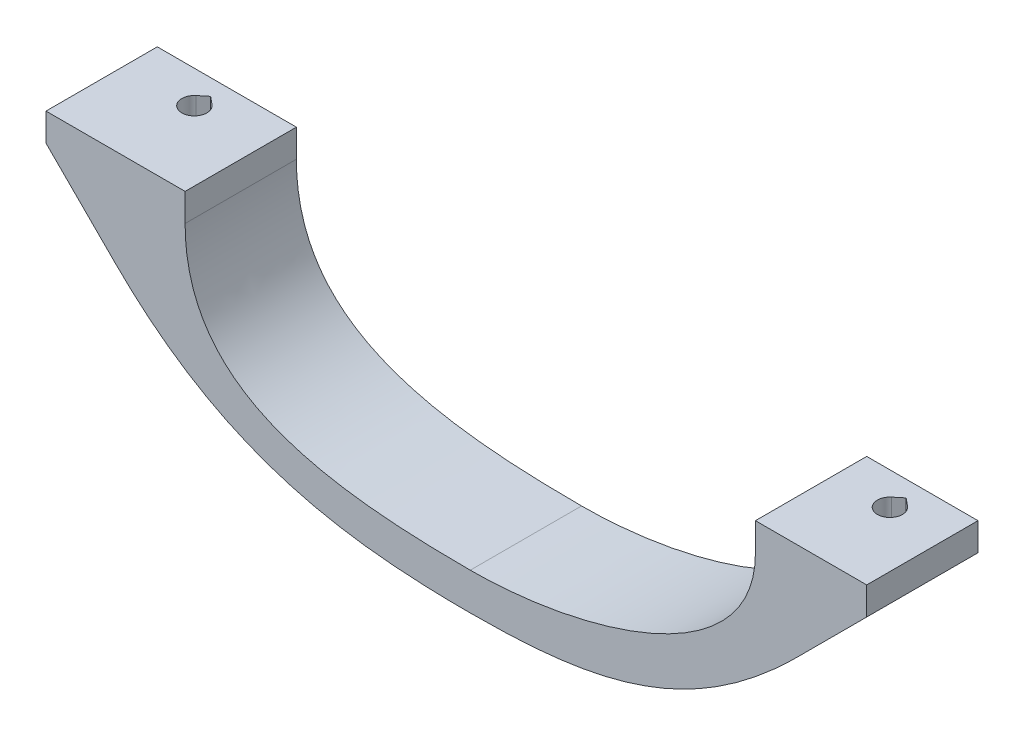
from build123d import *

# Parameters (mm, degrees)
BOSS_EXTRUDE1_DEPTH = 12
SKETCH2_R           = 1.35
CUT_EXTRUDE1_DEPTH  = 25.0000001
SKETCH4_R           = 2.5
CUT_EXTRUDE3_DEPTH  = 37
CUT_EXTRUDE4_DEPTH  = 25.0000001
CUT_EXTRUDE5_DEPTH  = 25.0000001


with BuildPart() as part:
    # Sketch1 → Boss-Extrude1 (new body)
    with BuildSketch(Plane.XY):
        with BuildLine():
            Line((88.5, -40), (76.5, -40))
            Line((76.5, -40), (76.5, -43))
            add(Edge.make_bspline(
                [(76.5, -43), (76.5, -54.661574252), (58.353185223, -60), (45.75, -60)],
                knots=[0, 0, 0, 0, 1, 1, 1, 1], degree=3))
            add(Edge.make_bspline(
                [(15, -43), (15, -57.889510146), (29.668022887, -60), (45.75, -60)],
                knots=[0, 0, 0, 0, 1, 1, 1, 1], degree=3))
            Line((15, -43), (15, -40))
            Line((15, -40), (0, -40))
            Line((0, -40), (0, -43))
            Line((0, -43), (7.5, -50.5))
            add(Edge.make_bspline(
                [(7.5, -50.5), (19.073181247, -62.073181247), (31.728934499, -64), (45.75, -64)],
                knots=[0, 0, 0, 0, 1, 1, 1, 1], degree=3))
            add(Edge.make_bspline(
                [(81, -50.5), (69.44210318, -62.05789682), (59.019901197, -64), (45.75, -64)],
                knots=[0, 0, 0, 0, 1, 1, 1, 1], degree=3))
            Line((81, -50.5), (88.5, -43))
            Line((88.5, -43), (88.5, -40))
        make_face()
    extrude(amount=-BOSS_EXTRUDE1_DEPTH)

    # Sketch2 → Cut-Extrude1 (cut, through all)
    with BuildSketch(Plane(origin=(0, -40, 0), x_dir=(1, 0, 0), z_dir=(0, 1, 0))):
        with Locations((82.5, 8.5)):
            Circle(SKETCH2_R)
        with Locations((7.5, 8.5)):
            Circle(SKETCH2_R)
    extrude(amount=-CUT_EXTRUDE1_DEPTH, mode=Mode.SUBTRACT)

    # Sketch4 → Cut-Extrude3 (cut)
    with BuildSketch(Plane(origin=(0, -80, 0), x_dir=(1, 0, 0), z_dir=(0, 1, 0))):
        with Locations((7.5, 8.5)):
            Circle(SKETCH4_R)
        with Locations((82.5, 8.5)):
            Circle(SKETCH4_R)
    extrude(amount=CUT_EXTRUDE3_DEPTH, mode=Mode.SUBTRACT)

    # Sketch7 → Cut-Extrude4 (cut, through all)
    with BuildSketch(Plane(origin=(0, -40, 0), x_dir=(1, 0, 0), z_dir=(0, 1, 0))):
        with BuildLine():
            Line((7.5, 10.25), (8.359026502, 9.541428571))
            ThreePointArc((8.359026502, 9.541428571), (7.5, 9.85), (6.640973498, 9.541428571))
            Line((6.640973498, 9.541428571), (7.5, 10.25))
        make_face()
    extrude(amount=-CUT_EXTRUDE4_DEPTH, mode=Mode.SUBTRACT)

    # Sketch8 → Cut-Extrude5 (cut, through all)
    with BuildSketch(Plane(origin=(0, -40, 0), x_dir=(1, 0, 0), z_dir=(0, 1, 0))):
        with BuildLine():
            Line((82.5, 10.25), (83.359026502, 9.541428571))
            ThreePointArc((83.359026502, 9.541428571), (82.5, 9.85), (81.640973498, 9.541428571))
            Line((81.640973498, 9.541428571), (82.5, 10.25))
        make_face()
    extrude(amount=-CUT_EXTRUDE5_DEPTH, mode=Mode.SUBTRACT)


solid = part.part
